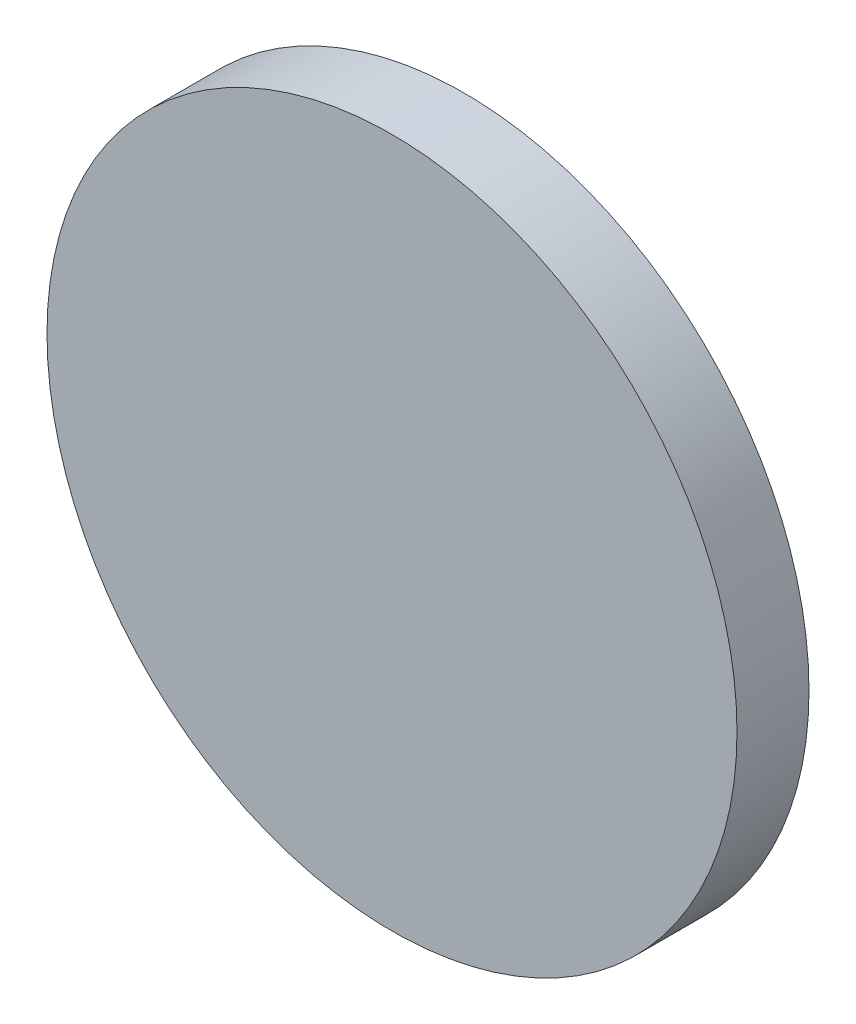
from build123d import *

# Parameters (mm, degrees)
SKETCH1_R           = 115
BOSS_EXTRUDE1_DEPTH = 24


with BuildPart() as part:
    # Sketch1 → Boss-Extrude1 (new body)
    with BuildSketch(Plane.XY):
        Circle(SKETCH1_R)
    extrude(amount=BOSS_EXTRUDE1_DEPTH)


solid = part.part
